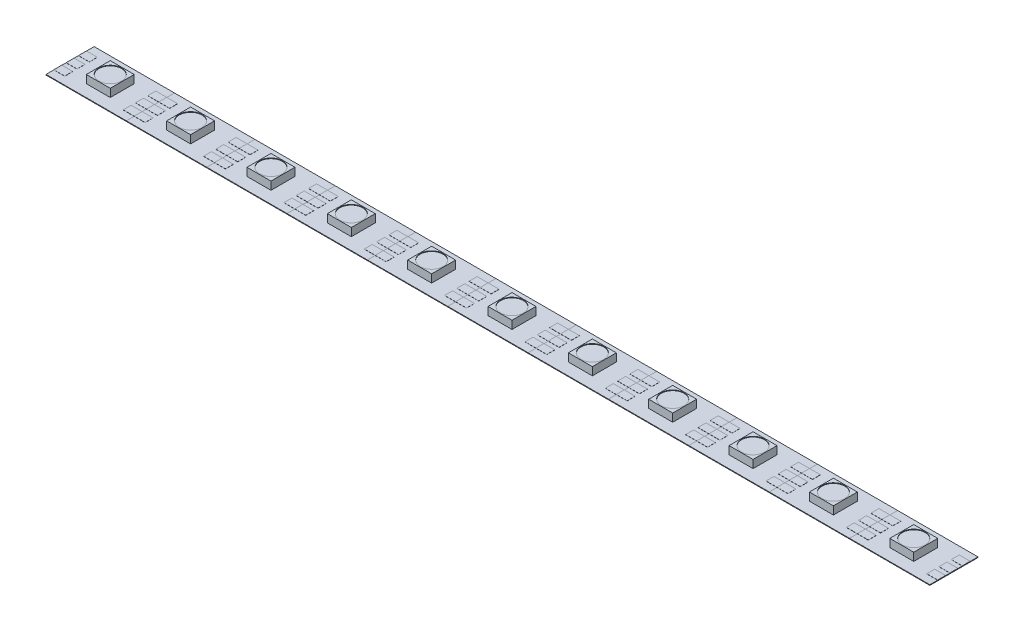
from build123d import *

# Parameters (mm, degrees)
SKETCH1_W           = 16.6116
SKETCH1_H           = 9.9568
BOSS_EXTRUDE1_DEPTH = 0.127
SKETCH3_W           = 4.953
SKETCH3_H           = 4.953
BOSS_EXTRUDE3_DEPTH = 1.651
SKETCH4_W           = 2.258810151
SKETCH4_H           = 1.651
BOSS_EXTRUDE4_DEPTH = 0.0254
SKETCH5_R           = 2.348345572
CUT_EXTRUDE1_DEPTH  = 0.127
LPATTERN1_COUNT     = 11
LPATTERN1_PITCH     = 16.6116


with BuildPart() as part:
    # Sketch1 → Boss-Extrude1 (new body)
    with BuildSketch(Plane(origin=(0, 0, 0), x_dir=(1, 0, 0), z_dir=(0, 1, 0))):
        Rectangle(SKETCH1_W, SKETCH1_H)
    extrude(amount=BOSS_EXTRUDE1_DEPTH)

    # Sketch3 → Boss-Extrude3 (add)
    with BuildSketch(Plane(origin=(0, 0.127, 0), x_dir=(1, 0, 0), z_dir=(0, 1, 0))):
        Rectangle(SKETCH3_W, SKETCH3_H)
    extrude(amount=BOSS_EXTRUDE3_DEPTH)

    # Sketch4 → Boss-Extrude4 (add)
    with BuildSketch(Plane(origin=(0, 0.127, 0), x_dir=(1, 0, 0), z_dir=(0, 1, 0))):
        with Locations((-7.176394925, 0)):
            Rectangle(SKETCH4_W, SKETCH4_H)
        with Locations((-7.176394925, 2.54)):
            Rectangle(SKETCH4_W, SKETCH4_H)
        with Locations((-7.176394925, -2.54)):
            Rectangle(SKETCH4_W, SKETCH4_H)
        with Locations((7.176394925, -2.54)):
            Rectangle(SKETCH4_W, SKETCH4_H)
        with Locations((7.176394925, 0)):
            Rectangle(SKETCH4_W, SKETCH4_H)
        with Locations((7.176394925, 2.54)):
            Rectangle(SKETCH4_W, SKETCH4_H)
    extrude(amount=BOSS_EXTRUDE4_DEPTH)

    # Sketch5 → Cut-Extrude1 (cut)
    with BuildSketch(Plane(origin=(0, 1.778, 0), x_dir=(1, 0, 0), z_dir=(0, 1, 0))):
        Circle(SKETCH5_R)
    extrude(amount=-CUT_EXTRUDE1_DEPTH, mode=Mode.SUBTRACT)


with BuildPart() as lpattern1_1:
    # LPattern1: pattern copy
    add(part.part.moved(Location(Vector(1, 0, 0) * (1 * LPATTERN1_PITCH))))


with BuildPart() as lpattern1_2:
    # LPattern1: pattern copy
    add(part.part.moved(Location(Vector(1, 0, 0) * (2 * LPATTERN1_PITCH))))


with BuildPart() as lpattern1_3:
    # LPattern1: pattern copy
    add(part.part.moved(Location(Vector(1, 0, 0) * (3 * LPATTERN1_PITCH))))


with BuildPart() as lpattern1_4:
    # LPattern1: pattern copy
    add(part.part.moved(Location(Vector(1, 0, 0) * (4 * LPATTERN1_PITCH))))


with BuildPart() as lpattern1_5:
    # LPattern1: pattern copy
    add(part.part.moved(Location(Vector(1, 0, 0) * (5 * LPATTERN1_PITCH))))


with BuildPart() as lpattern1_6:
    # LPattern1: pattern copy
    add(part.part.moved(Location(Vector(1, 0, 0) * (6 * LPATTERN1_PITCH))))


with BuildPart() as lpattern1_7:
    # LPattern1: pattern copy
    add(part.part.moved(Location(Vector(1, 0, 0) * (7 * LPATTERN1_PITCH))))


with BuildPart() as lpattern1_8:
    # LPattern1: pattern copy
    add(part.part.moved(Location(Vector(1, 0, 0) * (8 * LPATTERN1_PITCH))))


with BuildPart() as lpattern1_9:
    # LPattern1: pattern copy
    add(part.part.moved(Location(Vector(1, 0, 0) * (9 * LPATTERN1_PITCH))))


with BuildPart() as lpattern1_10:
    # LPattern1: pattern copy
    add(part.part.moved(Location(Vector(1, 0, 0) * (10 * LPATTERN1_PITCH))))


solid = Compound([part.part, lpattern1_1.part, lpattern1_2.part, lpattern1_3.part, lpattern1_4.part, lpattern1_5.part, lpattern1_6.part, lpattern1_7.part, lpattern1_8.part, lpattern1_9.part, lpattern1_10.part])
